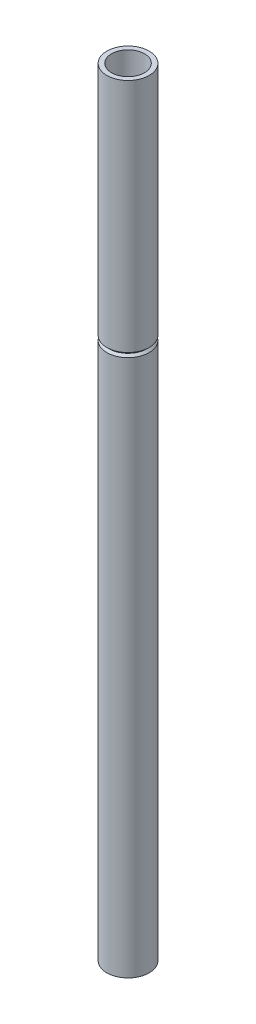
from build123d import *


with BuildPart() as part:
    # Sketch1 → Revolve-Thin1 (revolve)
    with BuildSketch(Plane.XY):
        Polygon((0.68, 25), (0.68, 17.420710678), (0.609289322, 17.35), (0.68, 17.279289322), (0.68, 0), (0.146556366, -0.187255024), (0.096873881, -0.04572181), (0.53, 0.106318699), (0.53, 17.217157288), (0.397157288, 17.35), (0.53, 17.482842712), (0.53, 25), align=None)
    revolve(axis=Axis((0, 0, 0), (0, 1, 0)))


solid = part.part
